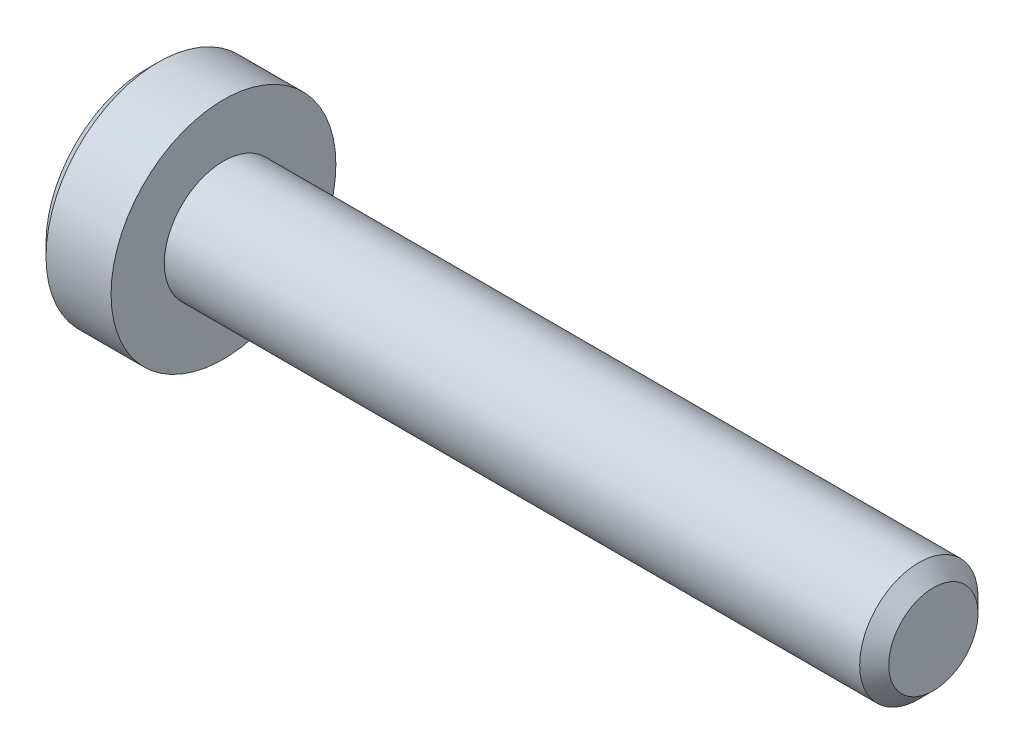
from build123d import *

# Parameters (mm, degrees)
CUT_EXTRUDE1_DEPTH = 0.7


with BuildPart() as part:
    # Sketch1 → Revolve1 (revolve)
    with BuildSketch(Plane.XY):
        Polygon((-1.3, 0), (-1.3, 1.7), (-1.1, 1.9), (0, 1.9), (0, 1), (11.7545, 1), (12, 0.7545), (12, 0), align=None)
    revolve(axis=Axis((12, 0, 0), (-1, 0, 0)))

    # Sketch2 → Cut-Extrude1 (cut)
    with BuildSketch(Plane(origin=(-1.3, 0, 0), x_dir=(0, 0, -1), z_dir=(1, 0, 0))):
        Polygon((-0.65, -0.375277675), (0, -0.75055535), (0.65, -0.375277675), (0.65, 0.375277675), (0, 0.75055535), (-0.65, 0.375277675), align=None)
    extrude(amount=CUT_EXTRUDE1_DEPTH, mode=Mode.SUBTRACT)


solid = part.part
